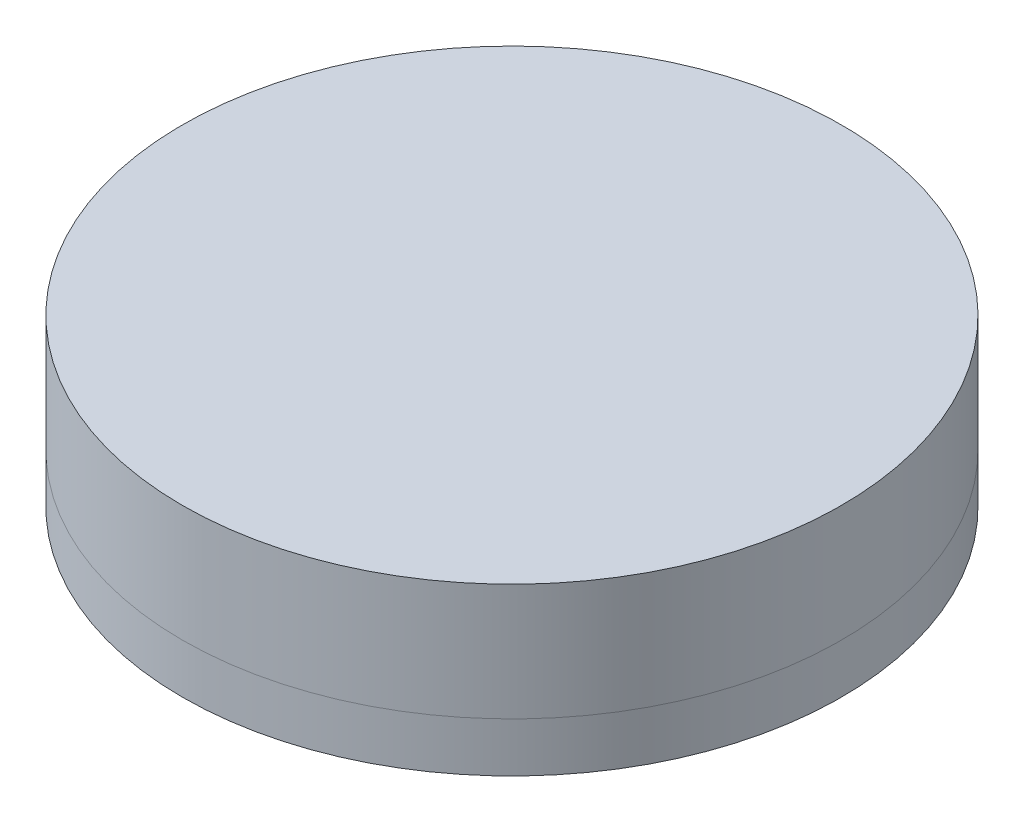
from build123d import *

# Parameters (mm, degrees)
SKETCH1_R           = 10
BOSS_EXTRUDE1_DEPTH = 3.54


with BuildPart() as part:
    # Sketch1 → Boss-Extrude1 (new body)
    with BuildSketch(Plane(origin=(0, 0, 0), x_dir=(1, 0, 0), z_dir=(0, 1, 0))):
        Circle(SKETCH1_R)
    extrude(amount=BOSS_EXTRUDE1_DEPTH)


with BuildPart() as body_2:
    # Sketch2 → Revolve17 (revolve)
    with BuildSketch(Plane.XY):
        with BuildLine():
            ThreePointArc((5.178300859, -1.5), (2.94423774, -0.476404004), (0.529378062, -0.021168333))
            Line((0.529378062, -0.021168333), (0.529378062, 0))
            Line((0.529378062, 0), (10, 0))
            Line((10, 0), (10, -1.5))
            Line((10, -1.5), (5.178300859, -1.5))
        make_face()
    revolve(axis=Axis((0, 3.314129783, 0), (0, -1, 0)))


solid = Compound([part.part, body_2.part])
